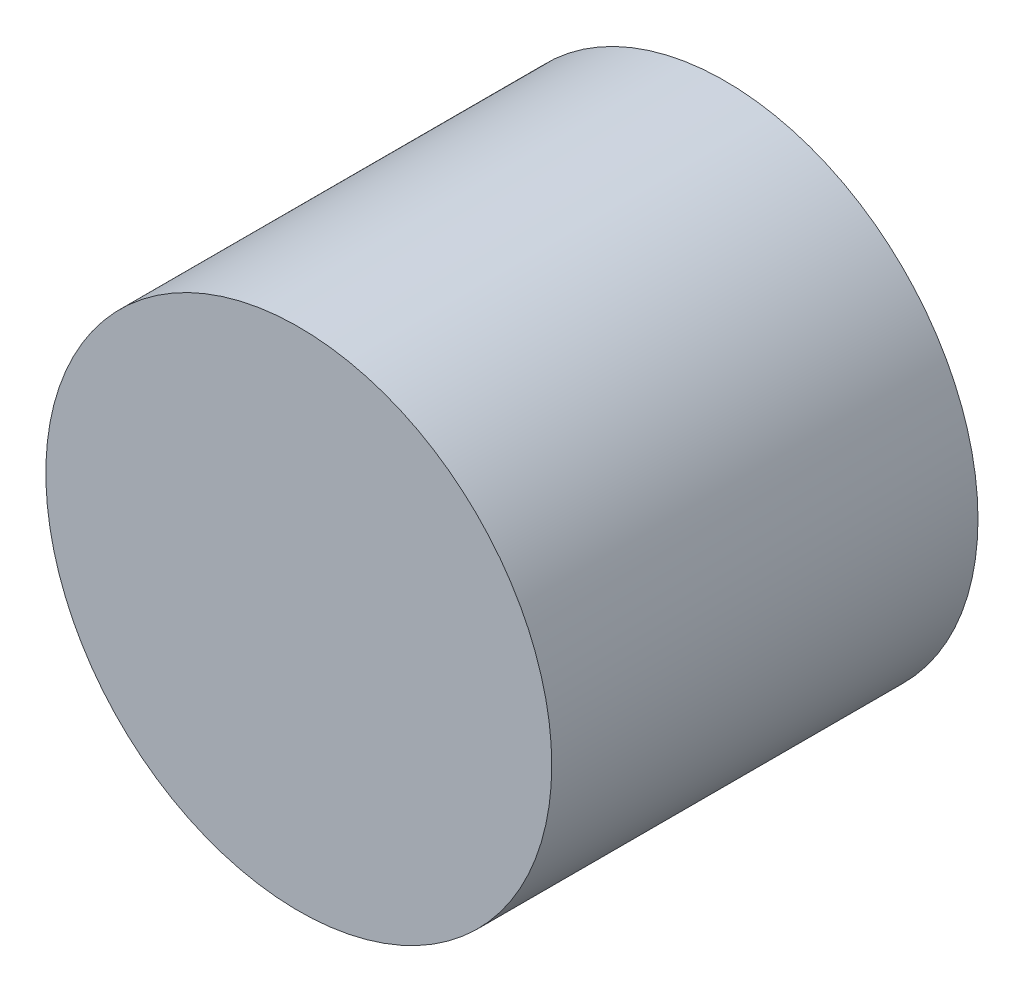
from build123d import *

# Parameters (mm, degrees)
SKETCH1_R           = 63.5
BOSS_EXTRUDE1_DEPTH = 107


with BuildPart() as part:
    # Sketch1 → Boss-Extrude1 (new body)
    with BuildSketch(Plane.XY):
        Circle(SKETCH1_R)
    extrude(amount=BOSS_EXTRUDE1_DEPTH)


solid = part.part
